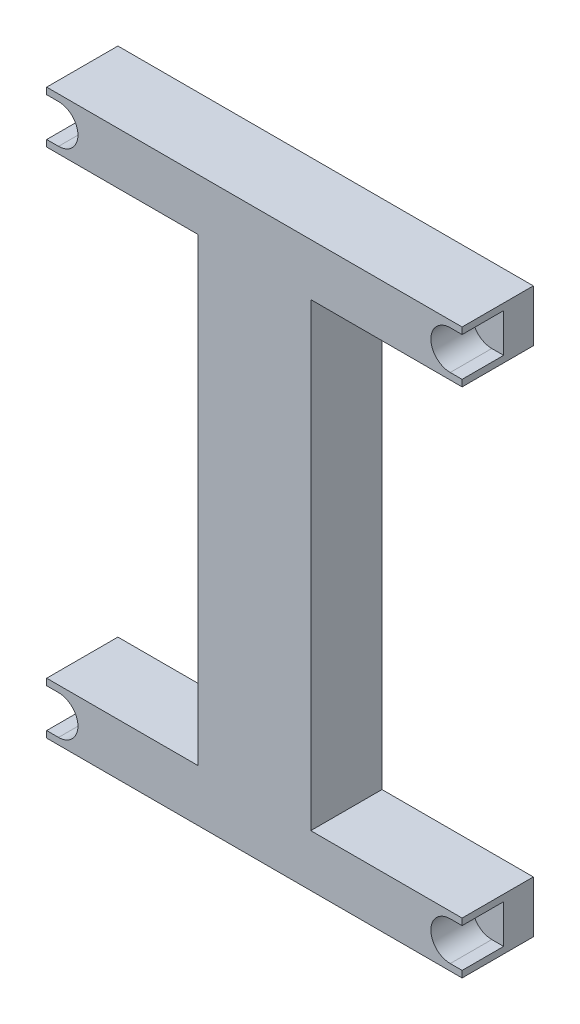
from build123d import *

# Parameters (mm, degrees)
SKETCH1_W           = 35
SKETCH1_H           = 155
SKETCH1_H_2         = 17.5
BOSS_EXTRUDE1_DEPTH = 24
SKETCH2_W           = 51
SKETCH2_H           = 77.5
CUT_EXTRUDE1_DEPTH  = 24
CUT_EXTRUDE2_DEPTH  = 14


with BuildPart() as part:
    # Sketch1 → Boss-Extrude1 (new body)
    with BuildSketch(Plane.XY):
        with Locations((-52.5, 0)):
            Rectangle(SKETCH1_W, SKETCH1_H)
        with Locations((-52.5, 86.25)):
            Rectangle(SKETCH1_W, SKETCH1_H_2)
        Polygon((35, 95), (-35, 95), (-35, 77.5), (-35, -77.5), (-35, -95), (35, -95), (35, -77.5), (35, 77.5), align=None)
        with Locations((52.5, 86.25)):
            Rectangle(SKETCH1_W, SKETCH1_H_2)
        with Locations((52.5, 0)):
            Rectangle(SKETCH1_W, SKETCH1_H)
        with Locations((52.5, -86.25)):
            Rectangle(SKETCH1_W, SKETCH1_H_2)
        with Locations((-52.5, -86.25)):
            Rectangle(SKETCH1_W, SKETCH1_H_2)
    extrude(amount=BOSS_EXTRUDE1_DEPTH)

    # Sketch2 → Cut-Extrude1 (cut)
    with BuildSketch(Plane.XY.offset(24)):
        with Locations((-44.5, 38.75)):
            Rectangle(SKETCH2_W, SKETCH2_H)
        with Locations((-44.5, -38.75)):
            Rectangle(SKETCH2_W, SKETCH2_H)
        Polygon((35, 77.5), (19, 77.5), (19, 0), (70, 0), (70, 77.5), align=None)
        Polygon((70, 0), (19, 0), (19, -77.5), (35, -77.5), (70, -77.5), align=None)
    extrude(amount=-CUT_EXTRUDE1_DEPTH, mode=Mode.SUBTRACT)

    # Sketch3 → Cut-Extrude2 (cut)
    with BuildSketch(Plane.XY.offset(24)):
        with BuildLine():
            Line((70, -92.781156562), (66, -92.781156562))
            ThreePointArc((66, -92.781156562), (59.468843438, -86.25), (66, -79.718843438))
            Line((66, -79.718843438), (70, -79.718843438))
            ThreePointArc((70, -79.718843438), (76.531156562, -86.25), (70, -92.781156562))
        make_face()
        with BuildLine():
            Line((70, 92.781156562), (66, 92.781156562))
            ThreePointArc((66, 92.781156562), (59.468843438, 86.25), (66, 79.718843438))
            Line((66, 79.718843438), (70, 79.718843438))
            ThreePointArc((70, 79.718843438), (76.531156562, 86.25), (70, 92.781156562))
        make_face()
        with BuildLine():
            Line((-70, 92.781156562), (-66, 92.781156562))
            ThreePointArc((-66, 92.781156562), (-59.468843438, 86.25), (-66, 79.718843438))
            Line((-66, 79.718843438), (-70, 79.718843438))
            ThreePointArc((-70, 79.718843438), (-76.531156562, 86.25), (-70, 92.781156562))
        make_face()
        with BuildLine():
            Line((-70, -92.781156562), (-66, -92.781156562))
            ThreePointArc((-66, -92.781156562), (-59.468843438, -86.25), (-66, -79.718843438))
            Line((-66, -79.718843438), (-70, -79.718843438))
            ThreePointArc((-70, -79.718843438), (-76.531156562, -86.25), (-70, -92.781156562))
        make_face()
    extrude(amount=-CUT_EXTRUDE2_DEPTH, mode=Mode.SUBTRACT)


solid = part.part
